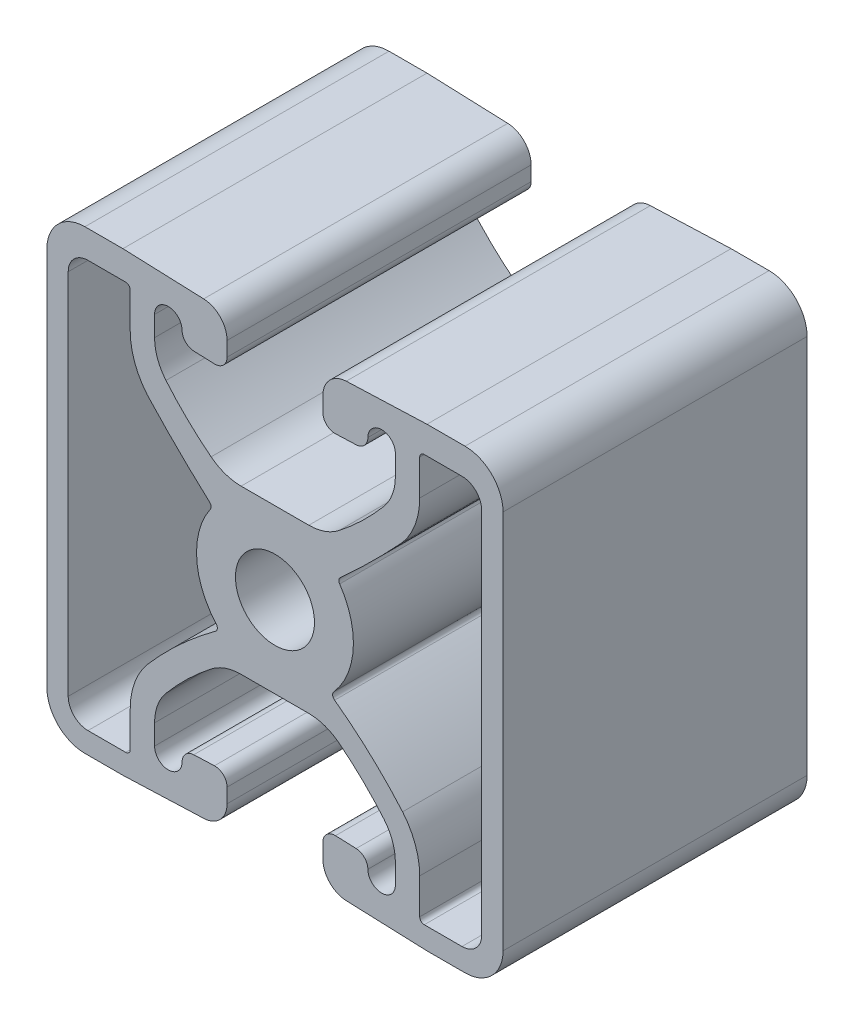
from build123d import *

# Parameters (mm, degrees)
EXTRUDE1_DEPTH = 25.4


with BuildPart() as part:
    # Sketch1 → Extrude1 (new body)
    with BuildSketch(Plane.XY):
        with BuildLine():
            Line((119.286543537, 134.961539124), (116.458442746, 134.961539124))
            Line((116.458442746, 134.961539124), (113.630341955, 134.961539124))
            ThreePointArc((113.630341955, 134.961539124), (112.303785999, 135.184140252), (111.122551329, 135.827558172))
            ThreePointArc((111.122551329, 135.827558172), (109.143601343, 137.551745223), (107.353147508, 139.470947948))
            ThreePointArc((107.353147508, 139.470947948), (106.645746382, 140.694329655), (106.400042746, 142.085986537))
            Line((106.400042746, 142.085986537), (106.400042746, 143.768987481))
            ThreePointArc((106.400042746, 143.768987481), (107.548393057, 144.918338688), (108.698744289, 143.770990147))
            ThreePointArc((108.698744289, 143.770990147), (108.983276863, 143.067626667), (109.675740732, 142.757509334))
            Line((109.675740732, 142.757509334), (111.402940732, 142.691157003))
            ThreePointArc((111.402940732, 142.691157003), (112.146439004, 142.974328196), (112.457942746, 143.706408126))
            Line((112.457942746, 143.706408126), (112.457942746, 144.914700752))
            ThreePointArc((112.457942746, 144.914700752), (111.890102605, 146.323693267), (110.503946774, 146.945202999))
            Line((110.503946774, 146.945202999), (103.758442746, 147.204339124))
            Line((103.758442746, 147.204339124), (100.583442746, 147.204339124))
            ThreePointArc((100.583442746, 147.204339124), (98.338378716, 146.274403155), (97.408442746, 144.029339124))
            Line((97.408442746, 144.029339124), (97.408442746, 112.279339124))
            ThreePointArc((97.408442746, 112.279339124), (98.338378716, 110.034275094), (100.583442746, 109.104339124))
            Line((100.583442746, 109.104339124), (103.758442746, 109.104339124))
            Line((103.758442746, 109.104339124), (110.503946774, 109.36347525))
            ThreePointArc((110.503946774, 109.36347525), (111.890102605, 109.984984981), (112.457942746, 111.393977496))
            Line((112.457942746, 111.393977496), (112.457942746, 112.602270123))
            ThreePointArc((112.457942746, 112.602270123), (112.146439004, 113.334350053), (111.402940732, 113.617521246))
            Line((111.402940732, 113.617521246), (109.675740732, 113.551168915))
            ThreePointArc((109.675740732, 113.551168915), (108.983276863, 113.241051582), (108.698744289, 112.537688102))
            ThreePointArc((108.698744289, 112.537688102), (107.548393057, 111.390339561), (106.400042746, 112.539690768))
            Line((106.400042746, 112.539690768), (106.400042746, 114.222691712))
            ThreePointArc((106.400042746, 114.222691712), (106.645746382, 115.614348594), (107.353147508, 116.8377303))
            ThreePointArc((107.353147508, 116.8377303), (109.143601343, 118.756933026), (111.122551329, 120.481120077))
            ThreePointArc((111.122551329, 120.481120077), (112.303785999, 121.124537997), (113.630341955, 121.347139124))
            Line((113.630341955, 121.347139124), (116.458442746, 121.347139124))
            Line((116.458442746, 121.347139124), (119.286543537, 121.347139124))
            ThreePointArc((119.286543537, 121.347139124), (120.613099494, 121.124537997), (121.794334164, 120.481120077))
            ThreePointArc((121.794334164, 120.481120077), (123.77328415, 118.756933026), (125.563737985, 116.8377303))
            ThreePointArc((125.563737985, 116.8377303), (126.27113911, 115.614348594), (126.516842746, 114.222691712))
            Line((126.516842746, 114.222691712), (126.516842746, 112.539690768))
            ThreePointArc((126.516842746, 112.539690768), (125.368492436, 111.390339561), (124.218141204, 112.537688102))
            ThreePointArc((124.218141204, 112.537688102), (123.93360863, 113.241051582), (123.24114476, 113.551168915))
            Line((123.24114476, 113.551168915), (121.51394476, 113.617521246))
            ThreePointArc((121.51394476, 113.617521246), (120.770446489, 113.334350053), (120.458942746, 112.602270123))
            Line((120.458942746, 112.602270123), (120.458942746, 111.393977496))
            ThreePointArc((120.458942746, 111.393977496), (121.026782887, 109.984984981), (122.412938718, 109.36347525))
            Line((122.412938718, 109.36347525), (129.158442746, 109.104339124))
            Line((129.158442746, 109.104339124), (132.333442746, 109.104339124))
            ThreePointArc((132.333442746, 109.104339124), (134.578506777, 110.034275094), (135.508442746, 112.279339124))
            Line((135.508442746, 112.279339124), (135.508442746, 144.029339124))
            ThreePointArc((135.508442746, 144.029339124), (134.578506777, 146.274403155), (132.333442746, 147.204339124))
            Line((132.333442746, 147.204339124), (129.158442746, 147.204339124))
            Line((129.158442746, 147.204339124), (122.412938718, 146.945202999))
            ThreePointArc((122.412938718, 146.945202999), (121.026782887, 146.323693267), (120.458942746, 144.914700752))
            Line((120.458942746, 144.914700752), (120.458942746, 143.706408126))
            ThreePointArc((120.458942746, 143.706408126), (120.770446489, 142.974328196), (121.51394476, 142.691157003))
            Line((121.51394476, 142.691157003), (123.24114476, 142.757509334))
            ThreePointArc((123.24114476, 142.757509334), (123.93360863, 143.067626667), (124.218141204, 143.770990147))
            ThreePointArc((124.218141204, 143.770990147), (125.368492436, 144.918338688), (126.516842746, 143.768987481))
            Line((126.516842746, 143.768987481), (126.516842746, 142.085986537))
            ThreePointArc((126.516842746, 142.085986537), (126.27113911, 140.694329655), (125.563737985, 139.470947948))
            ThreePointArc((125.563737985, 139.470947948), (123.77328415, 137.551745223), (121.794334164, 135.827558172))
            ThreePointArc((121.794334164, 135.827558172), (120.613099494, 135.184140252), (119.286543537, 134.961539124))
        make_face()
        with BuildLine():
            Line((128.548842746, 141.559935312), (128.548842746, 144.5192879))
            ThreePointArc((128.548842746, 144.5192879), (128.660435063, 144.788695584), (128.929842746, 144.9002879))
            Line((128.929842746, 144.9002879), (132.079442746, 144.9002879))
            ThreePointArc((132.079442746, 144.9002879), (133.246876042, 144.416721196), (133.730442746, 143.2492879))
            Line((133.730442746, 143.2492879), (133.730442746, 112.533339124))
            ThreePointArc((133.730442746, 112.533339124), (133.246876042, 111.365905829), (132.079442746, 110.882339124))
            Line((132.079442746, 110.882339124), (128.929842746, 110.882339124))
            ThreePointArc((128.929842746, 110.882339124), (128.660435063, 110.993931441), (128.548842746, 111.263339124))
            Line((128.548842746, 111.263339124), (128.548842746, 114.222691712))
            ThreePointArc((128.548842746, 114.222691712), (128.180287293, 116.310177035), (127.119185604, 118.145249594))
            ThreePointArc((127.119185604, 118.145249594), (124.427739509, 120.92409139), (121.44277505, 123.384951196))
            ThreePointArc((121.44277505, 123.384951196), (121.277666857, 123.652597781), (121.370025317, 123.953206039))
            ThreePointArc((121.370025317, 123.953206039), (122.999396104, 127.891050115), (121.862557266, 131.998246553))
            ThreePointArc((121.862557266, 131.998246553), (121.797364551, 132.248793719), (121.907342287, 132.483162808))
            ThreePointArc((121.907342287, 132.483162808), (124.57297323, 134.999893232), (127.119185604, 137.63737743))
            ThreePointArc((127.119185604, 137.63737743), (128.180287293, 139.47244999), (128.548842746, 141.559935312))
        make_face(mode=Mode.SUBTRACT)
        with BuildLine():
            Line((104.368042746, 141.559935312), (104.368042746, 144.5192879))
            ThreePointArc((104.368042746, 144.5192879), (104.25645043, 144.788695584), (103.987042746, 144.9002879))
            Line((103.987042746, 144.9002879), (100.837442746, 144.9002879))
            ThreePointArc((100.837442746, 144.9002879), (99.670009451, 144.416721196), (99.186442746, 143.2492879))
            Line((99.186442746, 143.2492879), (99.186442746, 112.533339124))
            ThreePointArc((99.186442746, 112.533339124), (99.670009451, 111.365905829), (100.837442746, 110.882339124))
            Line((100.837442746, 110.882339124), (103.987042746, 110.882339124))
            ThreePointArc((103.987042746, 110.882339124), (104.25645043, 110.993931441), (104.368042746, 111.263339124))
            Line((104.368042746, 111.263339124), (104.368042746, 114.222691712))
            ThreePointArc((104.368042746, 114.222691712), (104.7365982, 116.310177035), (105.797699889, 118.145249594))
            ThreePointArc((105.797699889, 118.145249594), (108.489145984, 120.92409139), (111.474110443, 123.384951196))
            ThreePointArc((111.474110443, 123.384951196), (111.639218636, 123.652597781), (111.546860176, 123.953206039))
            ThreePointArc((111.546860176, 123.953206039), (109.917489388, 127.891050115), (111.054328227, 131.998246553))
            ThreePointArc((111.054328227, 131.998246553), (111.119520942, 132.248793719), (111.009543206, 132.483162808))
            ThreePointArc((111.009543206, 132.483162808), (108.343912263, 134.999893232), (105.797699889, 137.63737743))
            ThreePointArc((105.797699889, 137.63737743), (104.7365982, 139.47244999), (104.368042746, 141.559935312))
        make_face(mode=Mode.SUBTRACT)
        with BuildLine():
            ThreePointArc((116.458442746, 131.456339124), (113.156442746, 128.154339124), (116.458442746, 124.852339124))
            ThreePointArc((116.458442746, 124.852339124), (119.760442746, 128.154339124), (116.458442746, 131.456339124))
        make_face(mode=Mode.SUBTRACT)
    extrude(amount=EXTRUDE1_DEPTH)


solid = part.part
